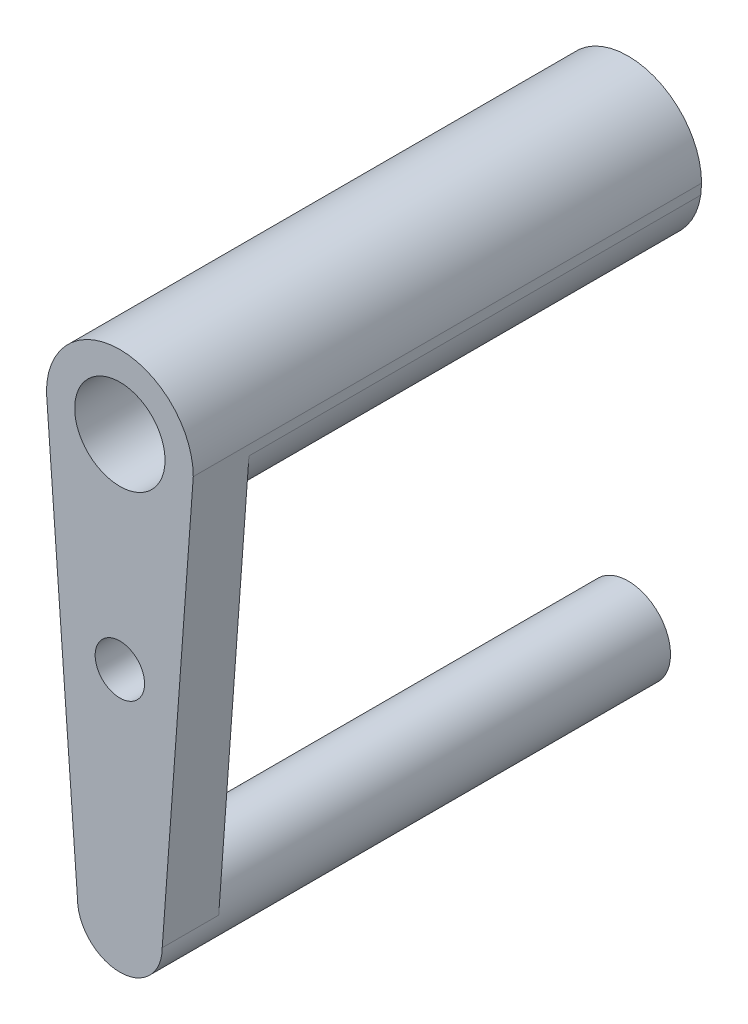
from build123d import *

# Parameters (mm, degrees)
SKETCH1_R           = 1.75
SKETCH1_R_2         = 3.2
BOSS_EXTRUDE1_DEPTH = 4
BOSS_EXTRUDE2_START = -32
SKETCH1_4_R         = 3
SKETCH1_4_R_2       = 3.2
BOSS_EXTRUDE2_DEPTH = 32


with BuildPart() as part:
    # Sketch1 → Boss-Extrude1 (new body)
    with BuildSketch(Plane.XY):
        with BuildLine():
            ThreePointArc((-3, -30), (0, -33), (3, -30))
            Line((3, -30), (5.2, 0))
            ThreePointArc((5.2, 0), (0, 5.2), (-5.2, 0))
            Line((-5.2, 0), (-3, -30))
        make_face()
        with Locations((0, -14.430389534)):
            Circle(SKETCH1_R, mode=Mode.SUBTRACT)
        Circle(SKETCH1_R_2, mode=Mode.SUBTRACT)
    extrude(amount=BOSS_EXTRUDE1_DEPTH)

    # Sketch1_4 → Boss-Extrude2 (add)
    # profile 1 of 2: a face of its own
    with BuildSketch(Plane.XY.offset(BOSS_EXTRUDE2_START)):
        with Locations((0, -30)):
            Circle(SKETCH1_4_R)
    # profile 2 of 2: a face of its own
    with BuildSketch(Plane.XY.offset(BOSS_EXTRUDE2_START)):
        with BuildLine():
            Line((-5.2, 0), (-5.144370275, -0.758587154))
            ThreePointArc((-5.144370275, -0.758587154), (0, -5.2), (5.144370275, -0.758587154))
            Line((5.144370275, -0.758587154), (5.2, 0))
            ThreePointArc((5.2, 0), (0, 5.2), (-5.2, 0))
        make_face()
        Circle(SKETCH1_4_R_2, mode=Mode.SUBTRACT)
    extrude(amount=BOSS_EXTRUDE2_DEPTH)


solid = part.part
